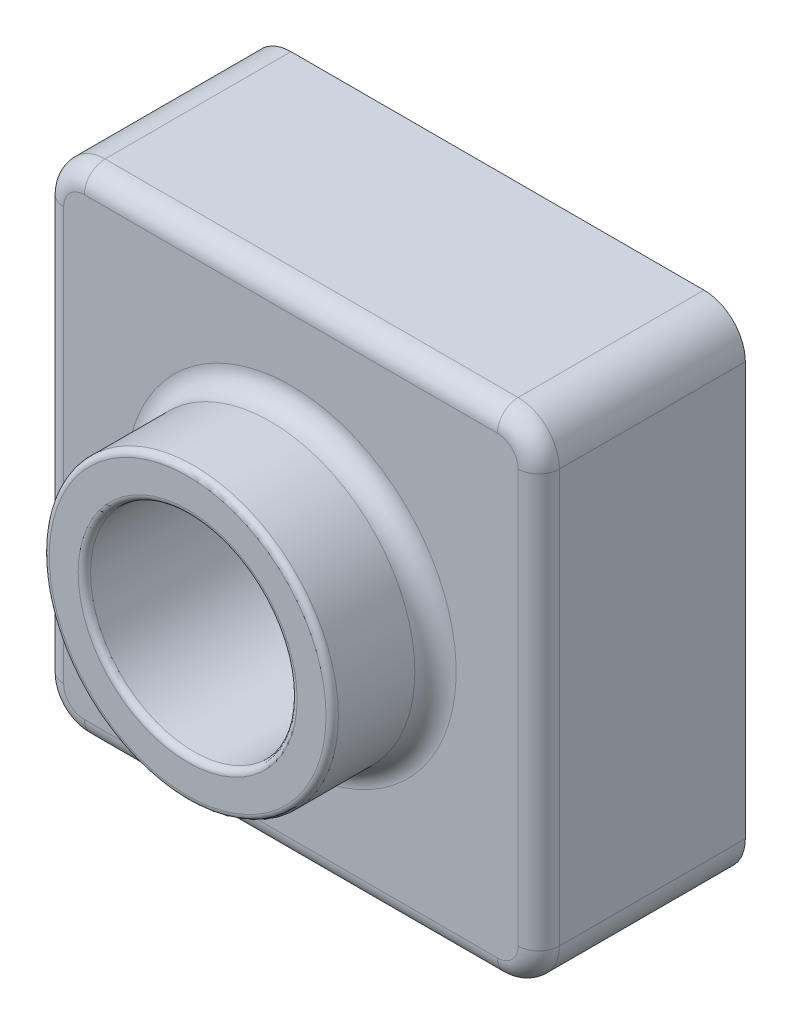
from build123d import *

# Parameters (mm, degrees)
SKETCH1_W           = 120
SKETCH1_H           = 120
BOSS_EXTRUDE1_DEPTH = 50
SKETCH2_R           = 35
BOSS_EXTRUDE2_DEPTH = 25
SKETCH6_R           = 25
CUT_EXTRUDE1_DEPTH  = 76
FILLET1_R           = 10
FILLET2_R           = 1.5
FILLET3_R           = 5
SHELL1_T            = -2


with BuildPart() as part:
    # Sketch1 → Boss-Extrude1 (new body)
    with BuildSketch(Plane.XY):
        with Locations((60, 60)):
            Rectangle(SKETCH1_W, SKETCH1_H)
    extrude(amount=BOSS_EXTRUDE1_DEPTH)

    # Sketch2 → Boss-Extrude2 (add)
    with BuildSketch(Plane.XY.offset(50)):
        with Locations((60, 60)):
            Circle(SKETCH2_R)
    extrude(amount=BOSS_EXTRUDE2_DEPTH)

    # Sketch6 → Cut-Extrude1 (cut, through all)
    with BuildSketch(Plane.XY.offset(75)):
        with Locations((60, 60)):
            Circle(SKETCH6_R)
    extrude(amount=-CUT_EXTRUDE1_DEPTH, mode=Mode.SUBTRACT)

    # Fillet1
    fillet1_edges = [part.edges().sort_by_distance(p)[0] for p in [
        (0, 120, 25),
        (120, 120, 25),
        (120, 0, 25),
        (0, 0, 25),
    ]]
    fillet(fillet1_edges, radius=FILLET1_R)

    # Fillet2
    fillet2_edges = [part.edges().sort_by_distance(p)[0] for p in [
        (25, 60, 75),
        (35, 60, 75),
    ]]
    fillet(fillet2_edges, radius=FILLET2_R)

    # Fillet3
    fillet3_edges = [part.edges().sort_by_distance(p)[0] for p in [
        (25, 60, 50),
        (60, 0, 50),
        (0, 60, 50),
        (120, 60, 50),
        (60, 120, 50),
        (2.928932188, 117.071067812, 50),
        (117.071067812, 117.071067812, 50),
        (117.071067812, 2.928932188, 50),
        (2.928932188, 2.928932188, 50),
    ]]
    fillet(fillet3_edges, radius=FILLET3_R)

    # Shell1
    shell1_openings = [part.faces().sort_by_distance(p)[0] for p in [
        (85, 60, 0),
    ]]
    offset(amount=SHELL1_T, openings=shell1_openings, kind=Kind.INTERSECTION)


solid = part.part
